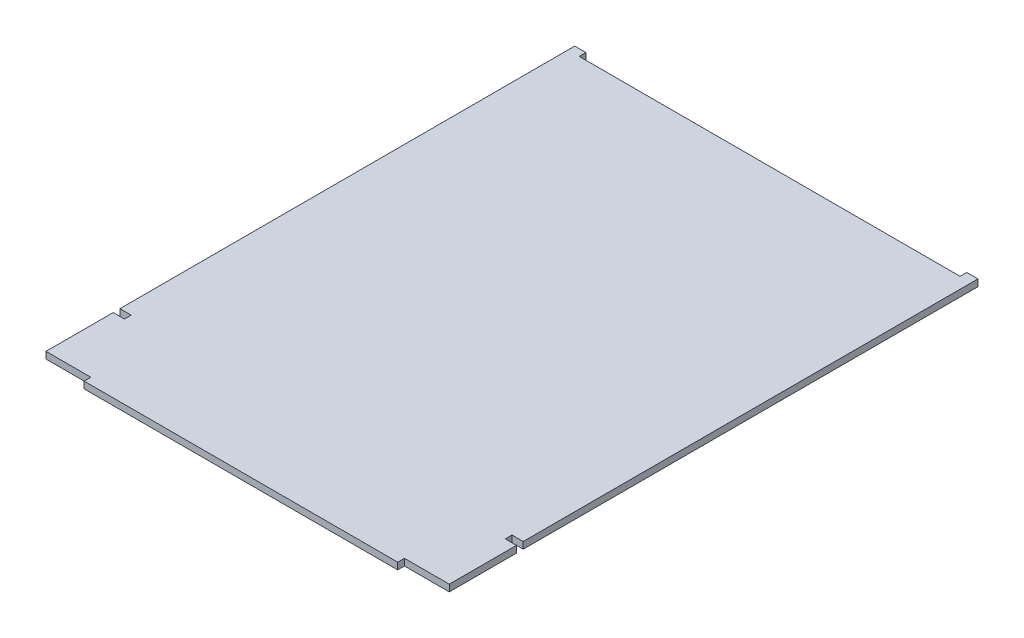
from build123d import *

# Parameters (mm, degrees)
EXTRUDE_1_DEPTH = 3


with BuildPart() as part:
    # 草图1 → 凸台-拉伸1 (new body)
    with BuildSketch(Plane(origin=(0, 0, 0), x_dir=(1, 0, 0), z_dir=(0, 1, 0))):
        Polygon((160, -3), (180, -3), (180, 0), (180, 27), (175, 27), (175, 30), (180, 30), (180, 230), (180, 233), (175, 233), (175, 230), (5, 230), (5, 233), (0, 233), (0, 230), (0, 30), (5, 30), (5, 27), (0, 27), (0, 0), (0, -3), (20, -3), (20, -6), (160, -6), align=None)
    extrude(amount=EXTRUDE_1_DEPTH)


solid = part.part
